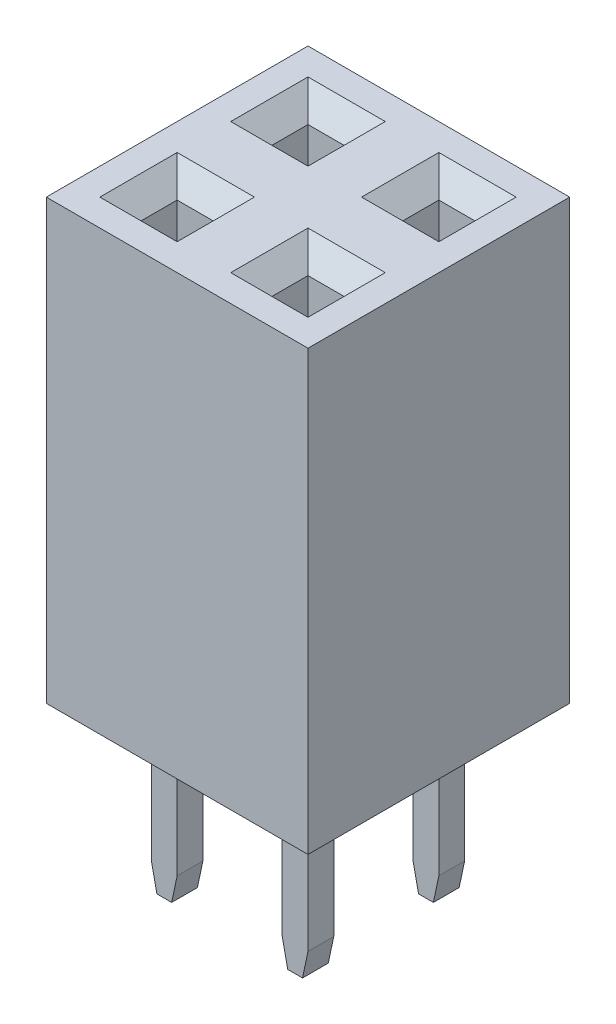
from build123d import *
from OCP.BRepFilletAPI import BRepFilletAPI_MakeChamfer

# Parameters (mm, degrees)
SKETCH_1_W                          = 2.54
SKETCH_1_H                          = 2.54
EXTRUDE_1_DEPTH                     = 8.51
SKETCH_4_W                          = 0.7
SKETCH_4_H                          = 0.7
CUT_EXTRUDE_1_DEPTH                 = 8.21
CHAMFER_3_SIZE                      = 0.4
SKETCH_2_W                          = 0.5
SKETCH_2_H                          = 0.5
EXTRUDE_2_DEPTH                     = 3.15
CHAMFER_2_SIZE                      = 0.5
CHAMFER_2_SIZE2                     = 0.106278281
PATTERN_LINEAR_1_COUNT              = 2
PATTERN_LINEAR_1_PITCH              = 2.54
PATTERN_LINEAR_1_COUNT_DIR2         = 2
PATTERN_LINEAR_1_PITCH_DIR2         = 2.54
CHAMFER_3_OF_PATTERN_LINEAR_1_SIZE  = 0.4
CHAMFER_2_OF_PATTERN_LINEAR_1_SIZE  = 0.5
CHAMFER_2_OF_PATTERN_LINEAR_1_SIZE2 = 0.106278281


with BuildPart() as part:
    # Эскиз1 → Бобышка-Вытянуть1 (new body)
    with BuildSketch(Plane(origin=(0, 0, 0), x_dir=(-1, 0, 0), z_dir=(0, 1, 0))):
        Rectangle(SKETCH_1_W, SKETCH_1_H)
    extrude_1 = extrude(amount=EXTRUDE_1_DEPTH)

    # Эскиз4 → Вырез-Вытянуть1 (cut)
    with BuildSketch(Plane(origin=(0, 8.51, 0), x_dir=(1, 0, 0), z_dir=(0, 1, 0))):
        Rectangle(SKETCH_4_W, SKETCH_4_H)
    cut_extrude_1 = extrude(amount=-CUT_EXTRUDE_1_DEPTH, mode=Mode.SUBTRACT)

    # Фаска3
    chamfer_3_edges = [part.edges().sort_by_distance(p)[0] for p in [
        (-0.35, 8.51, 0),
        (0, 8.51, 0.35),
        (0.35, 8.51, 0),
        (0, 8.51, -0.35),
    ]]
    chamfer(chamfer_3_edges, length=CHAMFER_3_SIZE)

    # Эскиз2 → Бобышка-Вытянуть2 (add)
    with BuildSketch(Plane(origin=(0, 0, 0), x_dir=(-1, 0, 0), z_dir=(0, 1, 0))):
        Rectangle(SKETCH_2_W, SKETCH_2_H)
    extrude_2 = extrude(amount=-EXTRUDE_2_DEPTH)

    # Фаска2: one chamfer whose edges measure the first distance from different faces: ONE call of the kernel's chamfer builder (chamfer() names one face for all edges)
    chamfer_2_edges_1 = [part.edges().sort_by_distance(p)[0] for p in [
        (-0.25, -3.15, 0),
    ]]
    chamfer_2_side_1 = [part.faces().sort_by_distance(p)[0] for p in [
        (-0.25, -1.575, 0),
    ]]
    chamfer_2_edges_2 = [part.edges().sort_by_distance(p)[0] for p in [
        (0.25, -3.15, 0),
    ]]
    chamfer_2_side_2 = [part.faces().sort_by_distance(p)[0] for p in [
        (0.25, -1.575, 0),
    ]]
    chamfer_2 = BRepFilletAPI_MakeChamfer(part.part.solid().wrapped)
    for e in chamfer_2_edges_1:
        chamfer_2.Add(CHAMFER_2_SIZE, CHAMFER_2_SIZE2, e.wrapped, chamfer_2_side_1[0].wrapped)  # the first distance lies on this face
    for e in chamfer_2_edges_2:
        chamfer_2.Add(CHAMFER_2_SIZE, CHAMFER_2_SIZE2, e.wrapped, chamfer_2_side_2[0].wrapped)  # the first distance lies on this face
    add(Compound.cast(chamfer_2.Shape()), mode=Mode.REPLACE)

    # Линейный массив1: Бобышка-Вытянуть1, Вырез-Вытянуть1, Extrude 2 2 × 2
    with Locations(*[(-j * PATTERN_LINEAR_1_PITCH_DIR2, 0, -i * PATTERN_LINEAR_1_PITCH) for i in range(PATTERN_LINEAR_1_COUNT) for j in range(PATTERN_LINEAR_1_COUNT_DIR2) if (i, j) != (0, 0)]):
        add(extrude_1)
        add(cut_extrude_1, mode=Mode.SUBTRACT)
        add(extrude_2)

    # Фаска3 of Линейный массив1
    chamfer_3_of_pattern_linear_1_edges = [part.edges().sort_by_distance(p)[0] for p in [
        (-2.89, 8.51, 0),
        (-2.54, 8.51, 0.35),
        (-2.19, 8.51, 0),
        (-2.54, 8.51, -0.35),
        (-0.35, 8.51, -2.54),
        (0, 8.51, -2.19),
        (0.35, 8.51, -2.54),
        (0, 8.51, -2.89),
        (-2.89, 8.51, -2.54),
        (-2.54, 8.51, -2.19),
        (-2.19, 8.51, -2.54),
        (-2.54, 8.51, -2.89),
    ]]
    chamfer(chamfer_3_of_pattern_linear_1_edges, length=CHAMFER_3_OF_PATTERN_LINEAR_1_SIZE)

    # Фаска2 of Линейный массив1: one chamfer whose edges measure the first distance from different faces: ONE call of the kernel's chamfer builder (chamfer() names one face for all edges)
    chamfer_2_of_pattern_linear_1_edges_1 = [part.edges().sort_by_distance(p)[0] for p in [
        (-2.79, -3.15, 0),
    ]]
    chamfer_2_of_pattern_linear_1_side_1 = [part.faces().sort_by_distance(p)[0] for p in [
        (-2.79, -1.575, 0),
    ]]
    chamfer_2_of_pattern_linear_1_edges_2 = [part.edges().sort_by_distance(p)[0] for p in [
        (-2.29, -3.15, 0),
    ]]
    chamfer_2_of_pattern_linear_1_side_2 = [part.faces().sort_by_distance(p)[0] for p in [
        (-2.29, -1.575, 0),
    ]]
    chamfer_2_of_pattern_linear_1_edges_3 = [part.edges().sort_by_distance(p)[0] for p in [
        (-0.25, -3.15, -2.54),
    ]]
    chamfer_2_of_pattern_linear_1_side_3 = [part.faces().sort_by_distance(p)[0] for p in [
        (-0.25, -1.575, -2.54),
    ]]
    chamfer_2_of_pattern_linear_1_edges_4 = [part.edges().sort_by_distance(p)[0] for p in [
        (0.25, -3.15, -2.54),
    ]]
    chamfer_2_of_pattern_linear_1_side_4 = [part.faces().sort_by_distance(p)[0] for p in [
        (0.25, -1.575, -2.54),
    ]]
    chamfer_2_of_pattern_linear_1_edges_5 = [part.edges().sort_by_distance(p)[0] for p in [
        (-2.79, -3.15, -2.54),
    ]]
    chamfer_2_of_pattern_linear_1_side_5 = [part.faces().sort_by_distance(p)[0] for p in [
        (-2.79, -1.575, -2.54),
    ]]
    chamfer_2_of_pattern_linear_1_edges_6 = [part.edges().sort_by_distance(p)[0] for p in [
        (-2.29, -3.15, -2.54),
    ]]
    chamfer_2_of_pattern_linear_1_side_6 = [part.faces().sort_by_distance(p)[0] for p in [
        (-2.29, -1.575, -2.54),
    ]]
    chamfer_2_of_pattern_linear_1 = BRepFilletAPI_MakeChamfer(part.part.solid().wrapped)
    for e in chamfer_2_of_pattern_linear_1_edges_1:
        chamfer_2_of_pattern_linear_1.Add(CHAMFER_2_OF_PATTERN_LINEAR_1_SIZE, CHAMFER_2_OF_PATTERN_LINEAR_1_SIZE2, e.wrapped, chamfer_2_of_pattern_linear_1_side_1[0].wrapped)  # the first distance lies on this face
    for e in chamfer_2_of_pattern_linear_1_edges_2:
        chamfer_2_of_pattern_linear_1.Add(CHAMFER_2_OF_PATTERN_LINEAR_1_SIZE, CHAMFER_2_OF_PATTERN_LINEAR_1_SIZE2, e.wrapped, chamfer_2_of_pattern_linear_1_side_2[0].wrapped)  # the first distance lies on this face
    for e in chamfer_2_of_pattern_linear_1_edges_3:
        chamfer_2_of_pattern_linear_1.Add(CHAMFER_2_OF_PATTERN_LINEAR_1_SIZE, CHAMFER_2_OF_PATTERN_LINEAR_1_SIZE2, e.wrapped, chamfer_2_of_pattern_linear_1_side_3[0].wrapped)  # the first distance lies on this face
    for e in chamfer_2_of_pattern_linear_1_edges_4:
        chamfer_2_of_pattern_linear_1.Add(CHAMFER_2_OF_PATTERN_LINEAR_1_SIZE, CHAMFER_2_OF_PATTERN_LINEAR_1_SIZE2, e.wrapped, chamfer_2_of_pattern_linear_1_side_4[0].wrapped)  # the first distance lies on this face
    for e in chamfer_2_of_pattern_linear_1_edges_5:
        chamfer_2_of_pattern_linear_1.Add(CHAMFER_2_OF_PATTERN_LINEAR_1_SIZE, CHAMFER_2_OF_PATTERN_LINEAR_1_SIZE2, e.wrapped, chamfer_2_of_pattern_linear_1_side_5[0].wrapped)  # the first distance lies on this face
    for e in chamfer_2_of_pattern_linear_1_edges_6:
        chamfer_2_of_pattern_linear_1.Add(CHAMFER_2_OF_PATTERN_LINEAR_1_SIZE, CHAMFER_2_OF_PATTERN_LINEAR_1_SIZE2, e.wrapped, chamfer_2_of_pattern_linear_1_side_6[0].wrapped)  # the first distance lies on this face
    add(Compound.cast(chamfer_2_of_pattern_linear_1.Shape()), mode=Mode.REPLACE)


solid = part.part
